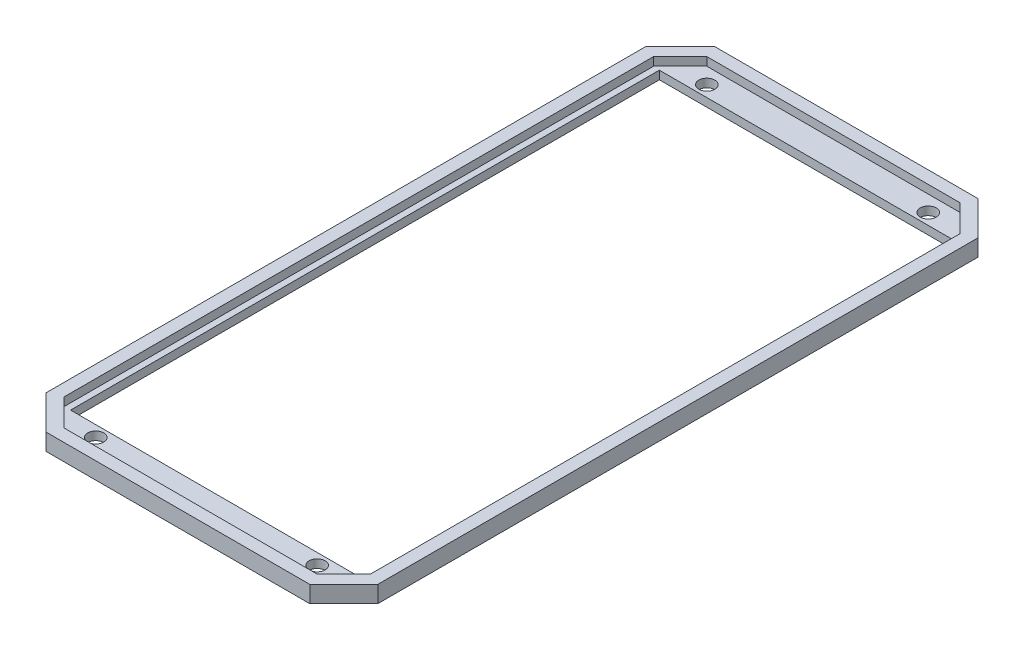
from build123d import *

# Parameters (mm, degrees)
SKETCH1_R           = 1.905
SKETCH1_W           = 70.15200002
SKETCH1_H           = 140.473361982
BOSS_EXTRUDE1_DEPTH = 2
BOSS_EXTRUDE2_DEPTH = 4


with BuildPart() as part:
    # Sketch1 → Boss-Extrude1 (new body)
    with BuildSketch(Plane(origin=(0, 0, 0), x_dir=(1, 0, 0), z_dir=(0, 1, 0))):
        Polygon((-27.256776842, -95.261534652), (-19.149417529, -87.154200597), (-19.149417529, 56.047080778), (-27.25676908, 64.16156963), (-90.194065977, 64.16156963), (-98.301422703, 56.047100861), (-98.301422703, -87.154180513), (-90.194058216, -95.261534652), align=None)
        with Locations((-85.141420182, -88.451514751)):
            Circle(SKETCH1_R, mode=Mode.SUBTRACT)
        with Locations((-58.725420192, -15.553513417)):
            Rectangle(SKETCH1_W, SKETCH1_H, mode=Mode.SUBTRACT)
        with Locations((-32.309420182, -88.451514751)):
            Circle(SKETCH1_R, mode=Mode.SUBTRACT)
        with Locations((-85.141420182, 57.344485249)):
            Circle(SKETCH1_R, mode=Mode.SUBTRACT)
        with Locations((-32.309420182, 57.344485249)):
            Circle(SKETCH1_R, mode=Mode.SUBTRACT)
    extrude(amount=BOSS_EXTRUDE1_DEPTH)

    # Sketch1_3 → Boss-Extrude2 (add)
    with BuildSketch(Plane(origin=(0, 0, 0), x_dir=(1, 0, 0), z_dir=(0, 1, 0))):
        Polygon((-27.256776842, -95.261534652), (-19.149417529, -87.154200597), (-19.149417529, 56.047080778), (-27.25676908, 64.16156963), (-90.194065977, 64.16156963), (-98.301422703, 56.047100861), (-98.301422703, -87.154180513), (-90.194058216, -95.261534652), align=None)
        Polygon((-22.14941613, 54.804442616), (-22.14941613, -85.911557384), (-28.499420182, -92.261514751), (-88.951420183, -92.261514751), (-95.301420183, -85.911514751), (-95.301420183, 54.804485249), (-88.951438098, 61.154505914), (-28.499624487, 61.154505914), align=None, mode=Mode.SUBTRACT)
    extrude(amount=BOSS_EXTRUDE2_DEPTH)


solid = part.part
